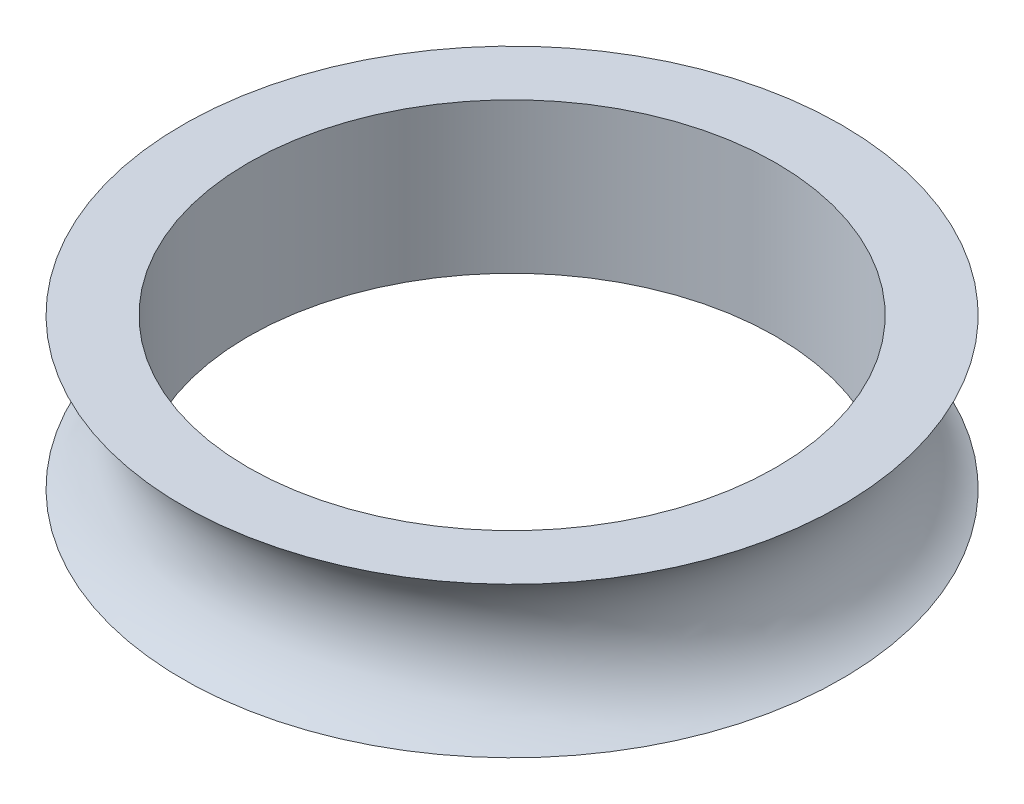
from build123d import *


with BuildPart() as part:
    # Sketch1 → Revolve1 (revolve)
    with BuildSketch(Plane.XY):
        with BuildLine():
            Line((14.05, 0), (17.55, 0))
            ThreePointArc((17.55, 0), (15.111552813, 4), (17.55, 8))
            Line((17.55, 8), (14.05, 8))
            Line((14.05, 8), (14.05, 0))
        make_face()
    revolve(axis=Axis((0, 0, 0), (0, 1, 0)))


solid = part.part
